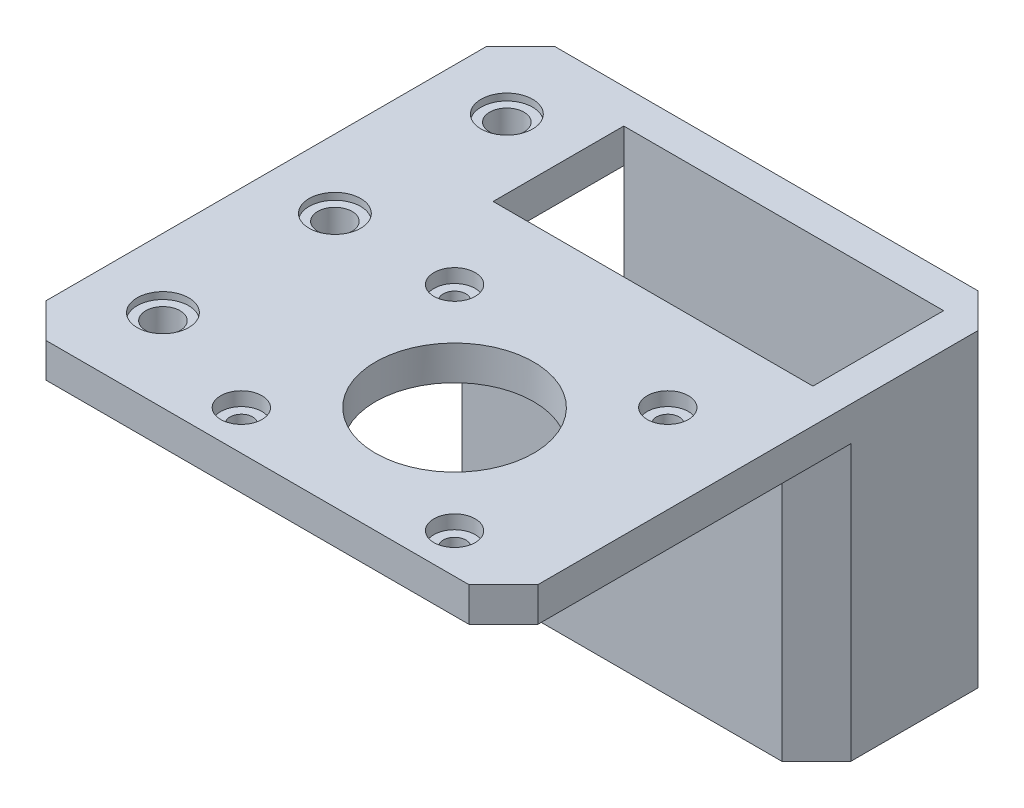
from build123d import *

# Parameters (mm, degrees)
SKETCH1_W           = 46.5
SKETCH1_H           = 19
SKETCH1_R           = 2.15
BOSS_EXTRUDE1_DEPTH = 5
BOSS_EXTRUDE2_DEPTH = 45
BOSS_EXTRUDE5_DEPTH = 5
CUT_EXTRUDE1_REACH  = 47
SKETCH7_R           = 11.5
SKETCH7_R_2         = 1.65
SKETCH8_W           = 24
SKETCH8_H           = 5
BOSS_EXTRUDE6_DEPTH = 20
CUT_EXTRUDE2_REACH  = 47
SKETCH9_R           = 2.5
CHAMFER1_SIZE       = 5
SKETCH10_R          = 3
CUT_EXTRUDE3_DEPTH  = 2
SKETCH12_R          = 3.75
CUT_EXTRUDE5_DEPTH  = 2
SKETCH13_R          = 3.75
CUT_EXTRUDE6_DEPTH  = 1


with BuildPart() as part:
    # Sketch1 → Boss-Extrude1 (new body)
    with BuildSketch(Plane(origin=(0, 0, 0), x_dir=(1, 0, 0), z_dir=(0, 1, 0))):
        Rectangle(SKETCH1_W, SKETCH1_H)
        with Locations((-18.5, 5)):
            Circle(SKETCH1_R, mode=Mode.SUBTRACT)
        with Locations((-18.5, -5)):
            Circle(SKETCH1_R, mode=Mode.SUBTRACT)
        with Locations((18.5, -5)):
            Circle(SKETCH1_R, mode=Mode.SUBTRACT)
        with Locations((18.5, 5)):
            Circle(SKETCH1_R, mode=Mode.SUBTRACT)
    extrude(amount=BOSS_EXTRUDE1_DEPTH)

    # Sketch2 → Boss-Extrude2 (add)
    with BuildSketch(Plane(origin=(0, 0, 0), x_dir=(1, 0, 0), z_dir=(0, 1, 0))):
        Polygon((28.25, 14.5), (28.25, -14), (-23.25, -14), (-23.25, -9.5), (23.25, -9.5), (23.25, 9.5), (-23.25, 9.5), (-23.25, 14.5), align=None)
    extrude(amount=BOSS_EXTRUDE2_DEPTH)

    # Sketch6 → Boss-Extrude5 (add)
    with BuildSketch(Plane(origin=(0, 45, 0), x_dir=(1, 0, 0), z_dir=(0, 1, 0))):
        Polygon((28.25, -14), (-23.25, -14), (-23.25, -9.5), (-43.25, -9.5), (-43.25, -59.5), (28.25, -59.5), align=None)
    extrude(amount=-BOSS_EXTRUDE5_DEPTH)

    # Sketch7 → Cut-Extrude1 (cut, up to next)
    with BuildSketch(Plane(origin=(0, 45, 0), x_dir=(1, 0, 0), z_dir=(0, 1, 0)), mode=Mode.PRIVATE) as cut_extrude1_sk1:
        with Locations((-0.1, -38.25)):
            Circle(SKETCH7_R)
    cut_extrude1_tool1 = extrude(cut_extrude1_sk1.sketch, amount=-CUT_EXTRUDE1_REACH, mode=Mode.PRIVATE) & part.part
    add(cut_extrude1_tool1.solids().sort_by_distance((-0.1, 45, 38.25))[0], mode=Mode.SUBTRACT)
    # Sketch7 → Cut-Extrude1 (cut, up to next)
    with BuildSketch(Plane(origin=(0, 45, 0), x_dir=(1, 0, 0), z_dir=(0, 1, 0)), mode=Mode.PRIVATE) as cut_extrude1_sk2:
        with Locations((-15.6, -22.75)):
            Circle(SKETCH7_R_2)
    cut_extrude1_tool2 = extrude(cut_extrude1_sk2.sketch, amount=-CUT_EXTRUDE1_REACH, mode=Mode.PRIVATE) & part.part
    add(cut_extrude1_tool2.solids().sort_by_distance((-15.6, 45, 22.75))[0], mode=Mode.SUBTRACT)
    # Sketch7 → Cut-Extrude1 (cut, up to next)
    with BuildSketch(Plane(origin=(0, 45, 0), x_dir=(1, 0, 0), z_dir=(0, 1, 0)), mode=Mode.PRIVATE) as cut_extrude1_sk3:
        with Locations((15.4, -22.75)):
            Circle(SKETCH7_R_2)
    cut_extrude1_tool3 = extrude(cut_extrude1_sk3.sketch, amount=-CUT_EXTRUDE1_REACH, mode=Mode.PRIVATE) & part.part
    add(cut_extrude1_tool3.solids().sort_by_distance((15.4, 45, 22.75))[0], mode=Mode.SUBTRACT)
    # Sketch7 → Cut-Extrude1 (cut, up to next)
    with BuildSketch(Plane(origin=(0, 45, 0), x_dir=(1, 0, 0), z_dir=(0, 1, 0)), mode=Mode.PRIVATE) as cut_extrude1_sk4:
        with Locations((15.4, -53.75)):
            Circle(SKETCH7_R_2)
    cut_extrude1_tool4 = extrude(cut_extrude1_sk4.sketch, amount=-CUT_EXTRUDE1_REACH, mode=Mode.PRIVATE) & part.part
    add(cut_extrude1_tool4.solids().sort_by_distance((15.4, 45, 53.75))[0], mode=Mode.SUBTRACT)
    # Sketch7 → Cut-Extrude1 (cut, up to next)
    with BuildSketch(Plane(origin=(0, 45, 0), x_dir=(1, 0, 0), z_dir=(0, 1, 0)), mode=Mode.PRIVATE) as cut_extrude1_sk5:
        with Locations((-15.6, -53.75)):
            Circle(SKETCH7_R_2)
    cut_extrude1_tool5 = extrude(cut_extrude1_sk5.sketch, amount=-CUT_EXTRUDE1_REACH, mode=Mode.PRIVATE) & part.part
    add(cut_extrude1_tool5.solids().sort_by_distance((-15.6, 45, 53.75))[0], mode=Mode.SUBTRACT)

    # Sketch8 → Boss-Extrude6 (add)
    with BuildSketch(Plane.ZY.offset(23.25)):
        with Locations((-2.5, 42.5)):
            Rectangle(SKETCH8_W, SKETCH8_H)
    extrude(amount=BOSS_EXTRUDE6_DEPTH)

    # Sketch9 → Cut-Extrude2 (cut, up to next)
    with BuildSketch(Plane(origin=(0, 45, 0), x_dir=(1, 0, 0), z_dir=(0, 1, 0)), mode=Mode.PRIVATE) as cut_extrude2_sk1:
        with Locations((-33.25, 2.5)):
            Circle(SKETCH9_R)
    cut_extrude2_tool1 = extrude(cut_extrude2_sk1.sketch, amount=-CUT_EXTRUDE2_REACH, mode=Mode.PRIVATE) & part.part
    add(cut_extrude2_tool1.solids().sort_by_distance((-33.25, 45, -2.5))[0], mode=Mode.SUBTRACT)
    # Sketch9 → Cut-Extrude2 (cut, up to next)
    with BuildSketch(Plane(origin=(0, 45, 0), x_dir=(1, 0, 0), z_dir=(0, 1, 0)), mode=Mode.PRIVATE) as cut_extrude2_sk2:
        with Locations((-33.25, -22.5)):
            Circle(SKETCH9_R)
    cut_extrude2_tool2 = extrude(cut_extrude2_sk2.sketch, amount=-CUT_EXTRUDE2_REACH, mode=Mode.PRIVATE) & part.part
    add(cut_extrude2_tool2.solids().sort_by_distance((-33.25, 45, 22.5))[0], mode=Mode.SUBTRACT)
    # Sketch9 → Cut-Extrude2 (cut, up to next)
    with BuildSketch(Plane(origin=(0, 45, 0), x_dir=(1, 0, 0), z_dir=(0, 1, 0)), mode=Mode.PRIVATE) as cut_extrude2_sk3:
        with Locations((-33.25, -47.5)):
            Circle(SKETCH9_R)
    cut_extrude2_tool3 = extrude(cut_extrude2_sk3.sketch, amount=-CUT_EXTRUDE2_REACH, mode=Mode.PRIVATE) & part.part
    add(cut_extrude2_tool3.solids().sort_by_distance((-33.25, 45, 47.5))[0], mode=Mode.SUBTRACT)

    # Chamfer1
    chamfer1_edges = [part.edges().sort_by_distance(p)[0] for p in [
        (28.25, 22.5, -14.5),
        (28.25, 20, 14),
        (-43.25, 42.5, 59.5),
        (28.25, 42.5, 59.5),
        (-43.25, 42.5, -14.5),
    ]]
    chamfer(chamfer1_edges, length=CHAMFER1_SIZE)

    # Sketch10 → Cut-Extrude3 (cut)
    with BuildSketch(Plane(origin=(0, 45, 0), x_dir=(1, 0, 0), z_dir=(0, 1, 0))):
        with Locations((-15.6, -22.75)):
            Circle(SKETCH10_R)
        with Locations((15.4, -22.75)):
            Circle(SKETCH10_R)
        with Locations((-15.6, -53.75)):
            Circle(SKETCH10_R)
        with Locations((15.4, -53.75)):
            Circle(SKETCH10_R)
    extrude(amount=-CUT_EXTRUDE3_DEPTH, mode=Mode.SUBTRACT)

    # Sketch12 → Cut-Extrude5 (cut)
    with BuildSketch(Plane.XZ):
        with Locations((-18.5, 5)):
            Circle(SKETCH12_R)
        with Locations((-18.5, -5)):
            Circle(SKETCH12_R)
        with Locations((18.5, -5)):
            Circle(SKETCH12_R)
        with Locations((18.5, 5)):
            Circle(SKETCH12_R)
    extrude(amount=-CUT_EXTRUDE5_DEPTH, mode=Mode.SUBTRACT)

    # Sketch13 → Cut-Extrude6 (cut)
    with BuildSketch(Plane(origin=(0, 45, 0), x_dir=(1, 0, 0), z_dir=(0, 1, 0))):
        with Locations((-33.25, 2.5)):
            Circle(SKETCH13_R)
        with Locations((-33.25, -22.5)):
            Circle(SKETCH13_R)
        with Locations((-33.25, -47.5)):
            Circle(SKETCH13_R)
    extrude(amount=-CUT_EXTRUDE6_DEPTH, mode=Mode.SUBTRACT)


solid = part.part
